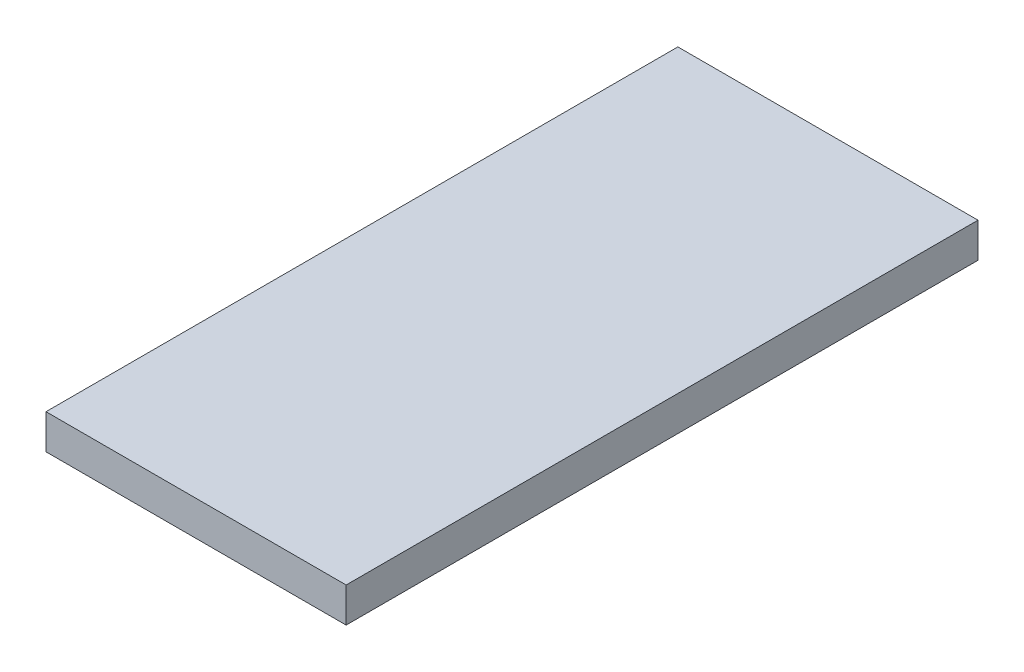
from build123d import *

# Parameters (mm, degrees)
SKETCH1_W           = 19
SKETCH1_H           = 2.2
BOSS_EXTRUDE1_DEPTH = 40


with BuildPart() as part:
    # Sketch1 → Boss-Extrude1 (new body)
    with BuildSketch(Plane.XY):
        Rectangle(SKETCH1_W, SKETCH1_H)
    extrude(amount=BOSS_EXTRUDE1_DEPTH)


solid = part.part
